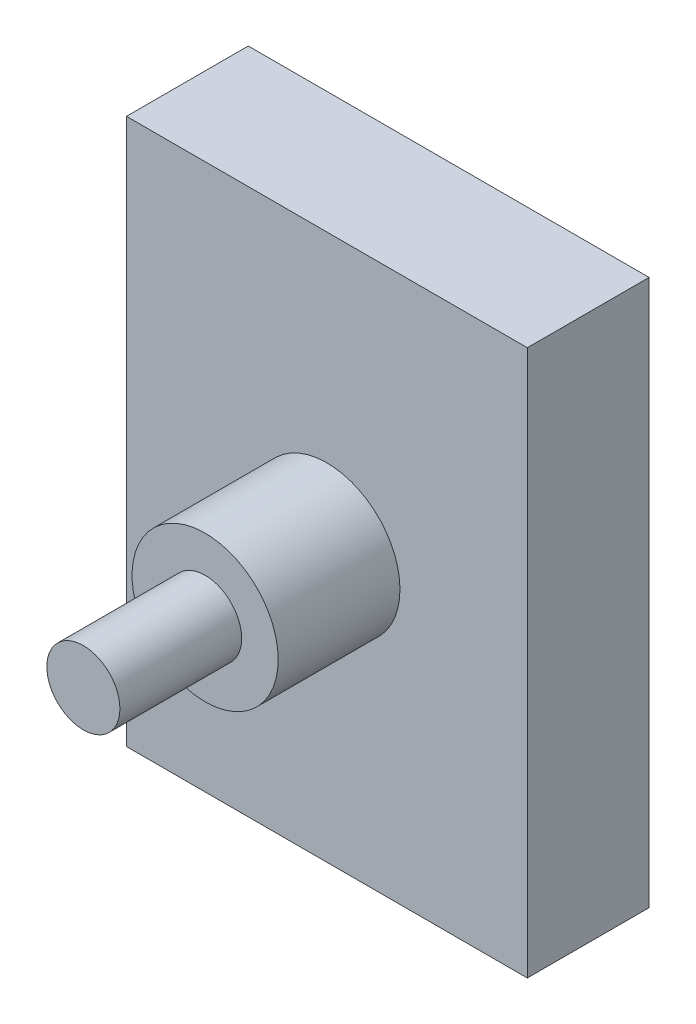
from build123d import *

# Parameters (mm, degrees)
SKETCH2_W           = 32.91869007
SKETCH2_H           = 44.826135242
BOSS_EXTRUDE1_DEPTH = 10
SKETCH3_R           = 6
BOSS_EXTRUDE2_DEPTH = 10
SKETCH4_R           = 3
BOSS_EXTRUDE3_DEPTH = 10


with BuildPart() as part:
    # Sketch2 → Boss-Extrude1 (new body)
    with BuildSketch(Plane.XY):
        Rectangle(SKETCH2_W, SKETCH2_H)
    extrude(amount=BOSS_EXTRUDE1_DEPTH)

    # Sketch3 → Boss-Extrude2 (add)
    with BuildSketch(Plane.XY.offset(10)):
        Circle(SKETCH3_R)
    extrude(amount=BOSS_EXTRUDE2_DEPTH)

    # Sketch4 → Boss-Extrude3 (add)
    with BuildSketch(Plane.XY.offset(20)):
        Circle(SKETCH4_R)
    extrude(amount=BOSS_EXTRUDE3_DEPTH)


solid = part.part
